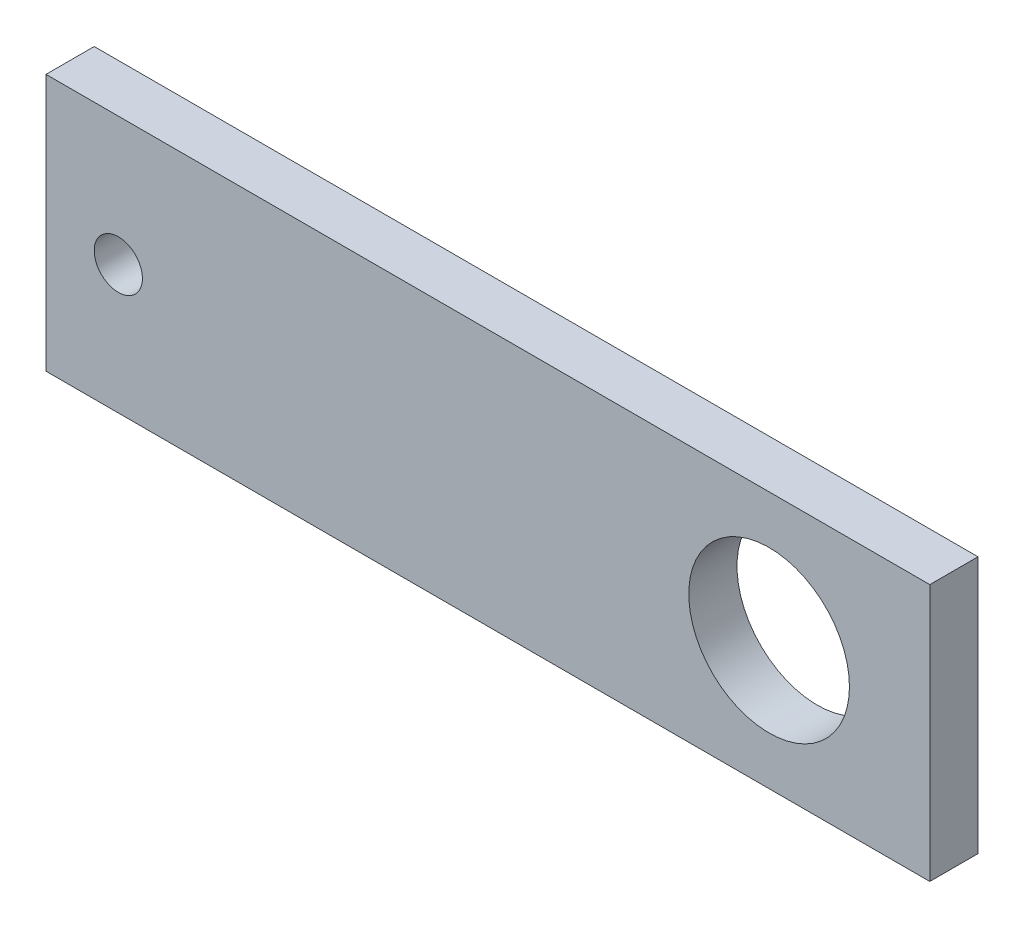
from build123d import *

# Parameters (mm, degrees)
ESQUISSE1_W        = 55
ESQUISSE1_H        = 16
ESQUISSE1_R        = 5
ESQUISSE1_R_2      = 1.5
BOSS_EXTRU_1_DEPTH = 3


with BuildPart() as part:
    # Esquisse1 → Boss.-Extru.1 (new body)
    with BuildSketch(Plane.XY):
        with Locations((-18.028289264, -7.249888765)):
            Rectangle(ESQUISSE1_W, ESQUISSE1_H)
        with Locations((-0.528289264, -7.249888765)):
            Circle(ESQUISSE1_R, mode=Mode.SUBTRACT)
        with Locations((-41.028289264, -7.249888765)):
            Circle(ESQUISSE1_R_2, mode=Mode.SUBTRACT)
    extrude(amount=BOSS_EXTRU_1_DEPTH)


solid = part.part
